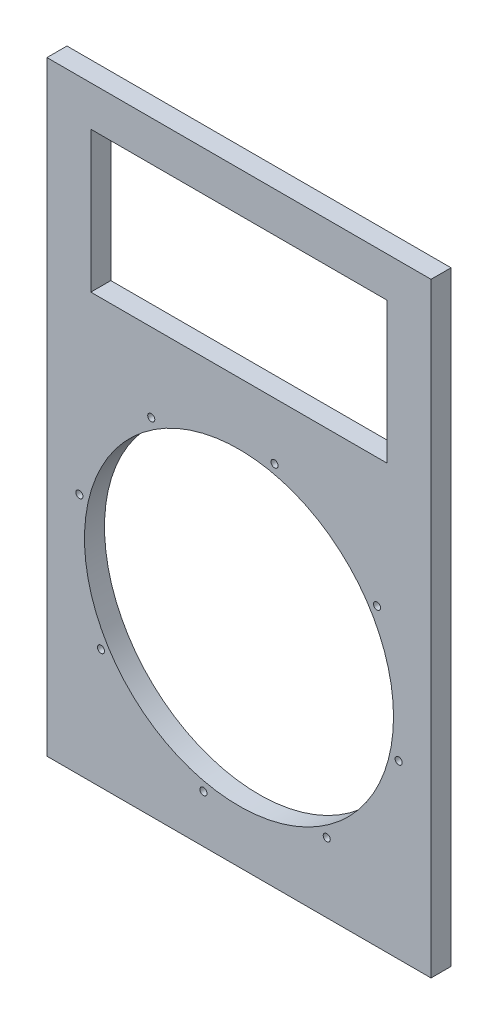
from build123d import *

# Parameters (mm, degrees)
SKETCH1_W           = 345.7
SKETCH1_H           = 544.6
BOSS_EXTRUDE1_DEPTH = 18
SKETCH2_W           = 266.7
SKETCH2_H           = 127
CUT_EXTRUDE1_DEPTH  = 19
SKETCH3_R           = 139.065
CUT_EXTRUDE2_DEPTH  = 19
SKETCH4_R           = 3.175
CUT_EXTRUDE3_DEPTH  = 19


with BuildPart() as part:
    # Sketch1 → Boss-Extrude1 (new body)
    with BuildSketch(Plane.XY):
        with Locations((172.85, 272.3)):
            Rectangle(SKETCH1_W, SKETCH1_H)
    extrude(amount=BOSS_EXTRUDE1_DEPTH)

    # Sketch2 → Cut-Extrude1 (cut, through all)
    with BuildSketch(Plane.XY.offset(18)):
        with Locations((172.85, 445)):
            Rectangle(SKETCH2_W, SKETCH2_H)
    extrude(amount=-CUT_EXTRUDE1_DEPTH, mode=Mode.SUBTRACT)

    # Sketch3 → Cut-Extrude2 (cut, through all)
    with BuildSketch(Plane.XY.offset(18)):
        with Locations((172.85, 186.690965799)):
            Circle(SKETCH3_R)
    extrude(amount=-CUT_EXTRUDE2_DEPTH, mode=Mode.SUBTRACT)

    # Sketch4 → Cut-Extrude3 (cut, through all)
    with BuildSketch(Plane.XY.offset(18)):
        with Locations((204.842157428, 330.365184475)):
            Circle(SKETCH4_R)
        with Locations((297.06488577, 265.662108644)):
            Circle(SKETCH4_R)
        with Locations((316.524218676, 154.698808371)):
            Circle(SKETCH4_R)
        with Locations((251.821142845, 62.476080029)):
            Circle(SKETCH4_R)
        with Locations((140.857842572, 43.016747123)):
            Circle(SKETCH4_R)
        with Locations((48.63511423, 107.719822954)):
            Circle(SKETCH4_R)
        with Locations((29.175781324, 218.683123227)):
            Circle(SKETCH4_R)
        with Locations((93.878857155, 310.905851569)):
            Circle(SKETCH4_R)
    extrude(amount=-CUT_EXTRUDE3_DEPTH, mode=Mode.SUBTRACT)


solid = part.part
